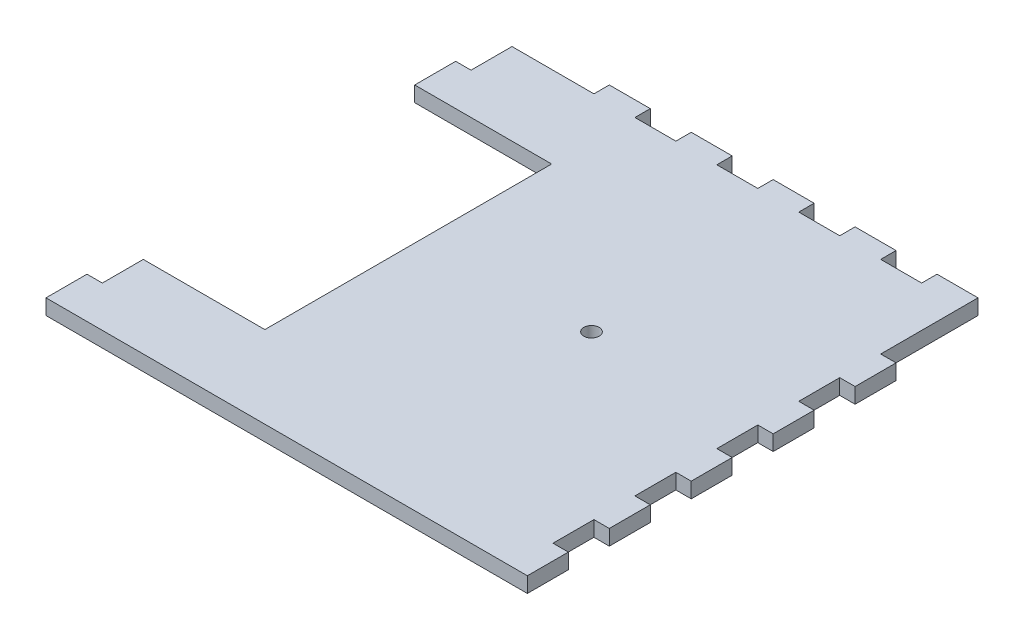
from build123d import *

# Parameters (mm, degrees)
SKETCH1_W               = 279.4
SKETCH1_H               = 279.4
BOSS_EXTRUDE1_DEPTH     = 9.525
SKETCH2_W               = 25.4
SKETCH2_H               = 9.525
BOSS_EXTRUDE2_DEPTH     = 9.525
LPATTERN1_COUNT         = 5
LPATTERN1_PITCH         = 50.8
MIRROR1_COPY_1_SKETCH_W = 25.4
MIRROR1_COPY_1_SKETCH_H = 9.525
MIRROR1_COPY_1_DEPTH    = 9.525
MIRROR1_COPY_2_SKETCH_W = 25.4
MIRROR1_COPY_2_SKETCH_H = 9.525
MIRROR1_COPY_2_DEPTH    = 9.525
MIRROR1_COPY_3_SKETCH_W = 25.4
MIRROR1_COPY_3_SKETCH_H = 9.525
MIRROR1_COPY_3_DEPTH    = 9.525
MIRROR1_COPY_4_SKETCH_W = 25.4
MIRROR1_COPY_4_SKETCH_H = 9.525
MIRROR1_COPY_4_DEPTH    = 9.525
SKETCH3_W               = 25.4
SKETCH3_H               = 9.525
BOSS_EXTRUDE3_DEPTH     = 9.525
LPATTERN2_COUNT         = 5
LPATTERN2_PITCH         = 50.8
SKETCH6_R               = 4.7625
CUT_EXTRUDE1_DEPTH      = 10.525
SKETCH8_W               = 84.891093183
SKETCH8_H               = 177.8
CUT_EXTRUDE3_DEPTH      = 10.525
SKETCH9_W               = 25.4
SKETCH9_H               = 9.525
BOSS_EXTRUDE4_DEPTH     = 9.525


with BuildPart() as part:
    # Sketch1 → Boss-Extrude1 (new body)
    with BuildSketch(Plane(origin=(0, 0, 0), x_dir=(1, 0, 0), z_dir=(0, 1, 0))):
        Rectangle(SKETCH1_W, SKETCH1_H)
    extrude(amount=BOSS_EXTRUDE1_DEPTH)

    # Sketch2 → Boss-Extrude2 (add)
    with BuildSketch(Plane(origin=(139.7, 0, 0), x_dir=(0, 0, -1), z_dir=(1, 0, 0))):
        with Locations((-127, 4.7625)):
            Rectangle(SKETCH2_W, SKETCH2_H)
    boss_extrude2 = extrude(amount=BOSS_EXTRUDE2_DEPTH)

    # LPattern1: Boss-Extrude2 ×5
    with Locations(*[(0, 0, -i * LPATTERN1_PITCH) for i in range(1, LPATTERN1_COUNT)]):
        add(boss_extrude2)

    # Mirror1: Boss-Extrude2 across plane
    add(boss_extrude2.mirror(Plane(origin=(0, 0, 0), x_dir=(0, 0, 1), z_dir=(1, 0, 0))))

    # Mirror1 copy 1 sketch → Mirror1 copy 1 (add)
    with BuildSketch(Plane(origin=(-139.7, 0, -50.8), x_dir=(0, 0, -1), z_dir=(-1, 0, 0))):
        with Locations((-127, -4.7625)):
            Rectangle(MIRROR1_COPY_1_SKETCH_W, MIRROR1_COPY_1_SKETCH_H)
    extrude(amount=MIRROR1_COPY_1_DEPTH)

    # Mirror1 copy 2 sketch → Mirror1 copy 2 (add)
    with BuildSketch(Plane(origin=(-139.7, 0, -101.6), x_dir=(0, 0, -1), z_dir=(-1, 0, 0))):
        with Locations((-127, -4.7625)):
            Rectangle(MIRROR1_COPY_2_SKETCH_W, MIRROR1_COPY_2_SKETCH_H)
    extrude(amount=MIRROR1_COPY_2_DEPTH)

    # Mirror1 copy 3 sketch → Mirror1 copy 3 (add)
    with BuildSketch(Plane(origin=(-139.7, 0, -152.4), x_dir=(0, 0, -1), z_dir=(-1, 0, 0))):
        with Locations((-127, -4.7625)):
            Rectangle(MIRROR1_COPY_3_SKETCH_W, MIRROR1_COPY_3_SKETCH_H)
    extrude(amount=MIRROR1_COPY_3_DEPTH)

    # Mirror1 copy 4 sketch → Mirror1 copy 4 (add)
    with BuildSketch(Plane(origin=(-139.7, 0, -203.2), x_dir=(0, 0, -1), z_dir=(-1, 0, 0))):
        with Locations((-127, -4.7625)):
            Rectangle(MIRROR1_COPY_4_SKETCH_W, MIRROR1_COPY_4_SKETCH_H)
    extrude(amount=MIRROR1_COPY_4_DEPTH)

    # Sketch3 → Boss-Extrude3 (add)
    with BuildSketch(Plane(origin=(0, 0, -139.7), x_dir=(-1, 0, 0), z_dir=(0, 0, -1))):
        with Locations((-127, 4.7625)):
            Rectangle(SKETCH3_W, SKETCH3_H)
    boss_extrude3 = extrude(amount=BOSS_EXTRUDE3_DEPTH)

    # LPattern2: Boss-Extrude3 ×5
    with Locations(*[(-i * LPATTERN2_PITCH, 0, 0) for i in range(1, LPATTERN2_COUNT)]):
        add(boss_extrude3)

    # Sketch6 → Cut-Extrude1 (cut, through all)
    with BuildSketch(Plane(origin=(0, 9.525, 0), x_dir=(1, 0, 0), z_dir=(0, 1, 0))):
        with Locations((38.1, 11.176)):
            Circle(SKETCH6_R)
    extrude(amount=-CUT_EXTRUDE1_DEPTH, mode=Mode.SUBTRACT)

    # Sketch8 → Cut-Extrude3 (cut, through all)
    with BuildSketch(Plane(origin=(0, 9.525, 0), x_dir=(1, 0, 0), z_dir=(0, 1, 0))):
        with Locations((-106.779453409, 0)):
            Rectangle(SKETCH8_W, SKETCH8_H)
    extrude(amount=-CUT_EXTRUDE3_DEPTH, mode=Mode.SUBTRACT)

    # Sketch9 → Boss-Extrude4 (add)
    with BuildSketch(Plane.ZY.offset(139.7)):
        with Locations((-101.6, 4.7625)):
            Rectangle(SKETCH9_W, SKETCH9_H)
    extrude(amount=BOSS_EXTRUDE4_DEPTH)


solid = part.part
